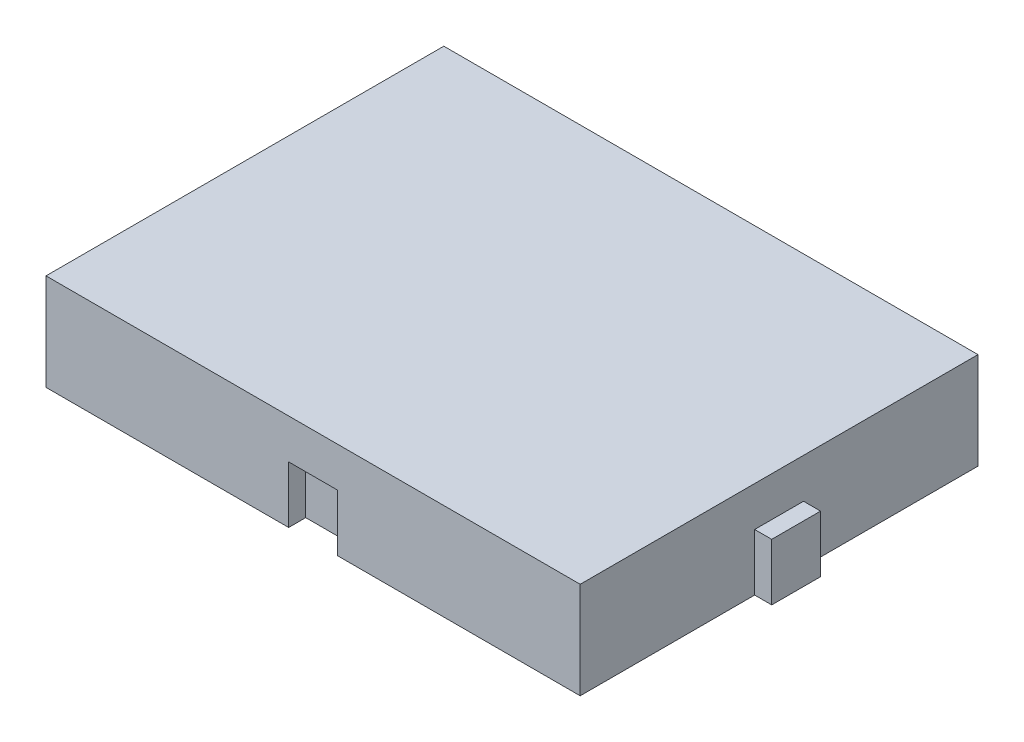
from build123d import *

# Parameters (mm, degrees)
SKETCH1_W           = 47
SKETCH1_H           = 35
BOSS_EXTRUDE1_DEPTH = 8.5
SKETCH2_W           = 4.3
SKETCH2_H           = 1.5
SKETCH2_W_2         = 1.5
SKETCH2_H_2         = 4.3
BOSS_EXTRUDE2_DEPTH = 5
SKETCH3_W           = 4.3
SKETCH3_H           = 1.5
SKETCH3_W_2         = 1.5
SKETCH3_H_2         = 4.3
CUT_EXTRUDE1_DEPTH  = 5


with BuildPart() as part:
    # Sketch1 → Boss-Extrude1 (new body)
    with BuildSketch(Plane(origin=(0, 0, 0), x_dir=(1, 0, 0), z_dir=(0, 1, 0))):
        Rectangle(SKETCH1_W, SKETCH1_H)
    extrude(amount=BOSS_EXTRUDE1_DEPTH)

    # Sketch2 → Boss-Extrude2 (add)
    with BuildSketch(Plane(origin=(0, 0, 0), x_dir=(-1, 0, 0), z_dir=(0, -1, 0))):
        with Locations((0, 18.25)):
            Rectangle(SKETCH2_W, SKETCH2_H)
        with Locations((-24.25, 0)):
            Rectangle(SKETCH2_W_2, SKETCH2_H_2)
    extrude(amount=-BOSS_EXTRUDE2_DEPTH)

    # Sketch3 → Cut-Extrude1 (cut)
    with BuildSketch(Plane(origin=(0, 0, 0), x_dir=(-1, 0, 0), z_dir=(0, -1, 0))):
        with Locations((0, -16.75)):
            Rectangle(SKETCH3_W, SKETCH3_H)
        with Locations((22.75, 0)):
            Rectangle(SKETCH3_W_2, SKETCH3_H_2)
    extrude(amount=-CUT_EXTRUDE1_DEPTH, mode=Mode.SUBTRACT)


solid = part.part
